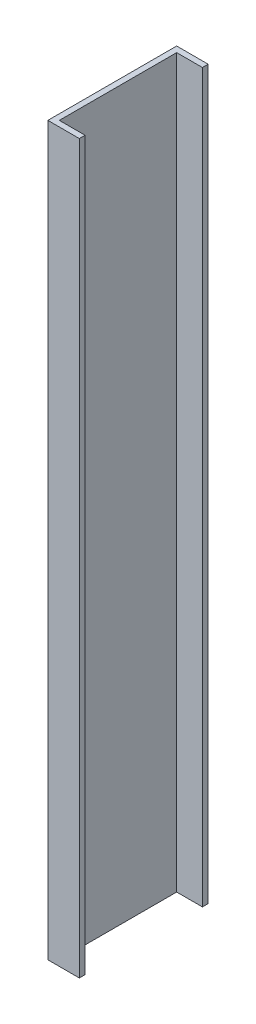
from build123d import *

# Parameters (mm, degrees)
BOSS_EXTRUDE1_DEPTH = 254


with BuildPart() as part:
    # Sketch1 → Boss-Extrude1 (new body)
    with BuildSketch(Plane(origin=(0, 0, 0), x_dir=(1, 0, 0), z_dir=(0, 1, 0))):
        Polygon((0, 0), (0, 45), (11, 45), (11, 43), (2, 43), (2, 2), (11, 2), (11, 0), align=None)
    extrude(amount=BOSS_EXTRUDE1_DEPTH)


solid = part.part
